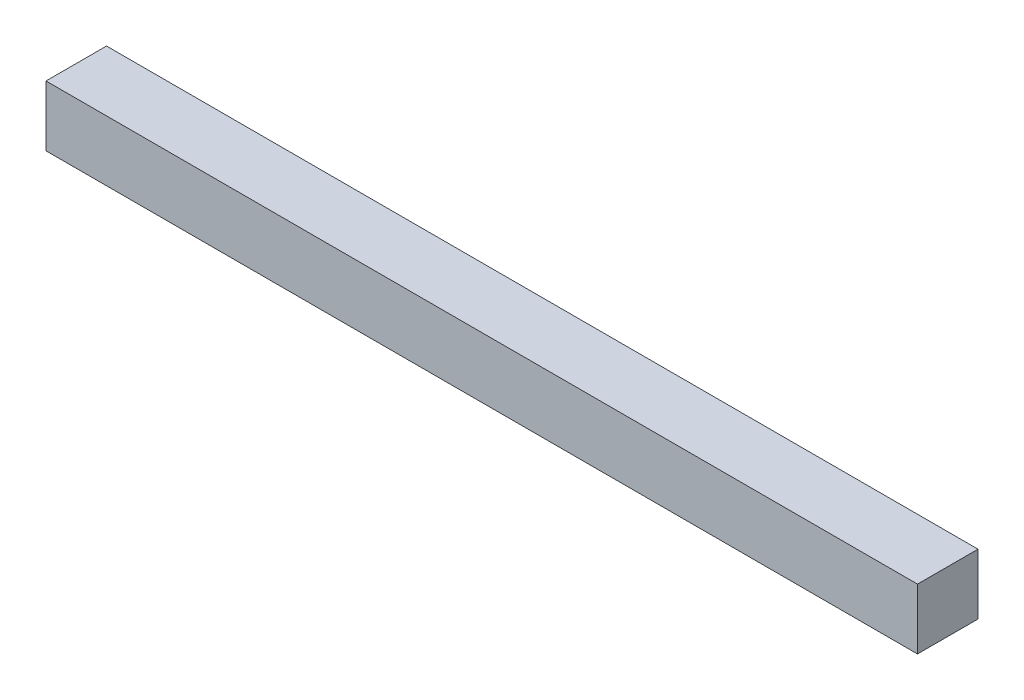
from build123d import *

# Parameters (mm, degrees)
SKETCH1_W           = 365.76
SKETCH1_H           = 25.4
BOSS_EXTRUDE1_DEPTH = 25.4


with BuildPart() as part:
    # Sketch1 → Boss-Extrude1 (new body)
    with BuildSketch(Plane(origin=(0, 0, 0), x_dir=(1, 0, 0), z_dir=(0, 1, 0))):
        with Locations((182.88, 12.7)):
            Rectangle(SKETCH1_W, SKETCH1_H)
    extrude(amount=BOSS_EXTRUDE1_DEPTH)


solid = part.part
